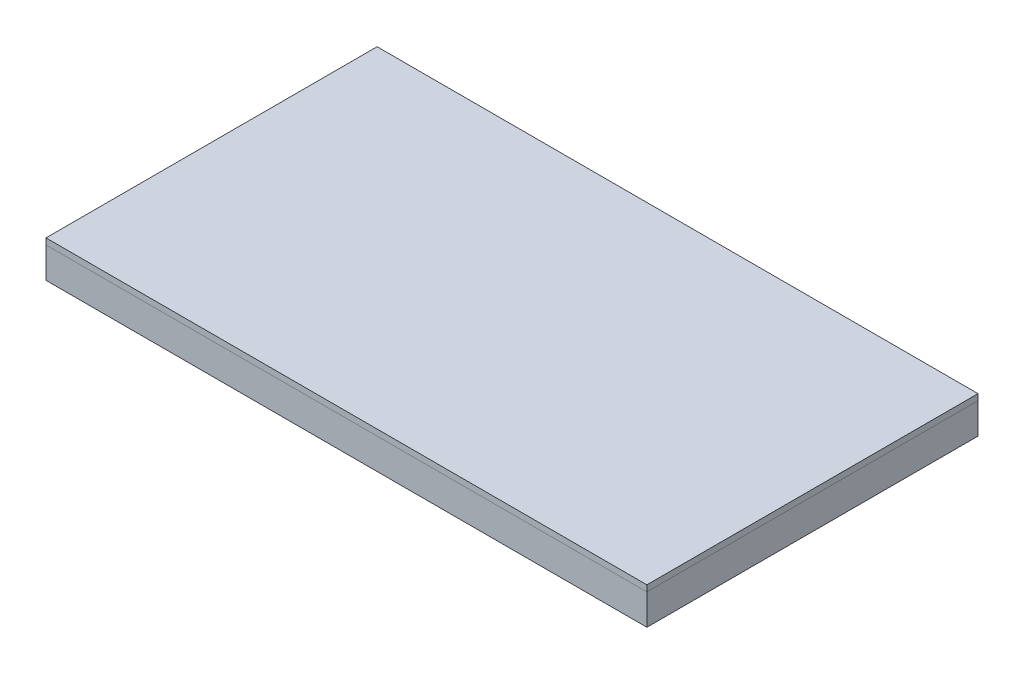
from build123d import *

# Parameters (mm, degrees)
SKETCH1_W           = 980
SKETCH1_H           = 540
BOSS_EXTRUDE1_DEPTH = 10
SKETCH1_3_W         = 980
SKETCH1_3_H         = 540
SKETCH1_3_W_2       = 960
SKETCH1_3_H_2       = 520
BOSS_EXTRUDE2_DEPTH = 50


with BuildPart() as part:
    # Sketch1 → Boss-Extrude1 (new body)
    with BuildSketch(Plane(origin=(0, 0, 0), x_dir=(1, 0, 0), z_dir=(0, 1, 0))):
        Rectangle(SKETCH1_W, SKETCH1_H)
    extrude(amount=BOSS_EXTRUDE1_DEPTH)


with BuildPart() as body_2:
    # Sketch1_3 → Boss-Extrude2 (new body)
    with BuildSketch(Plane(origin=(0, 0, 0), x_dir=(1, 0, 0), z_dir=(0, 1, 0))):
        Rectangle(SKETCH1_3_W, SKETCH1_3_H)
        Rectangle(SKETCH1_3_W_2, SKETCH1_3_H_2, mode=Mode.SUBTRACT)
    extrude(amount=-BOSS_EXTRUDE2_DEPTH)


solid = Compound([part.part, body_2.part])
